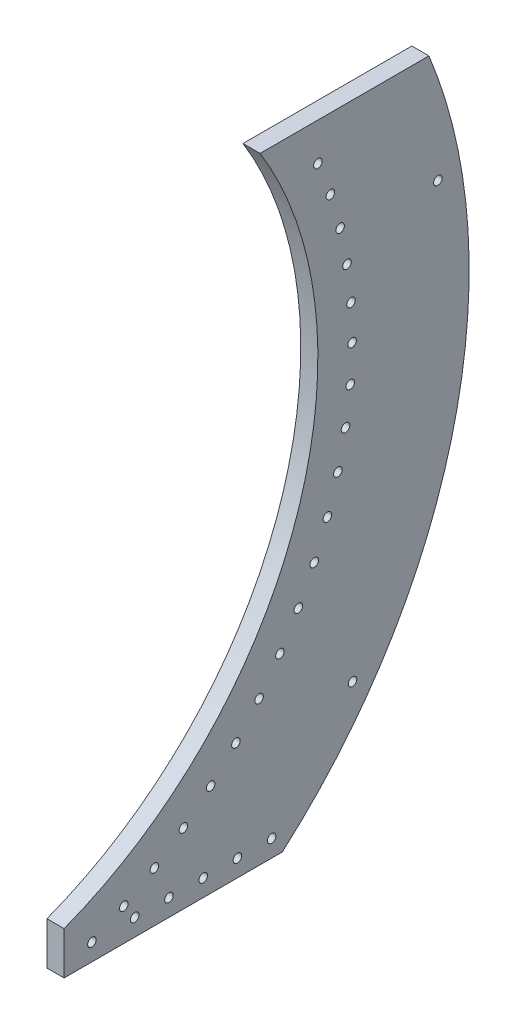
from build123d import *

# Parameters (mm, degrees)
BOSS_EXTRUDE1_DEPTH         = 12.7
SKETCH2_W                   = 323.85
SKETCH2_H                   = 152.4
CUT_EXTRUDE1_DEPTH          = 12.7
F_1_4_0_25_DIAMETER_HOLE1_D = 6.35
CUT_EXTRUDE2_DEPTH          = 13.7
SKETCH9_R                   = 3.175
CUT_EXTRUDE3_DEPTH          = 13.7
SKETCH10_R                  = 3.175
CUT_EXTRUDE4_DEPTH          = 13.7
LPATTERN1_COUNT             = 5
LPATTERN1_PITCH             = 25.4


with BuildPart() as part:
    # Sketch1 → Boss-Extrude1 (new body)
    with BuildSketch(Plane(origin=(0, 0, 0), x_dir=(0, 0, -1), z_dir=(1, 0, 0))):
        with BuildLine():
            Line((0, 609.6), (323.85, 609.6))
            Line((323.85, 609.6), (323.85, 0))
            Line((323.85, 0), (0, 0))
            Line((0, 0), (0, 31.75))
            ThreePointArc((0, 31.75), (188.340145046, 304.8), (0, 577.85))
            Line((0, 577.85), (0, 609.6))
        make_face()
    extrude(amount=BOSS_EXTRUDE1_DEPTH)

    # Sketch2 → Cut-Extrude1 (cut)
    with BuildSketch(Plane(origin=(12.7, 0, 0), x_dir=(0, 0, -1), z_dir=(1, 0, 0))):
        with Locations((161.925, 533.4)):
            Rectangle(SKETCH2_W, SKETCH2_H)
    extrude(amount=-CUT_EXTRUDE1_DEPTH, mode=Mode.SUBTRACT)

    # 1/4 (0.25) Diameter Hole1 (through all)
    with Locations(Plane(origin=(12.7, 0, 0), x_dir=(0, 0, -1), z_dir=(1, 0, 0))):
        with Locations((20.67422398, 12.7), (44.370645325, 23.973354386), (67.055185152, 37.165039515), (88.57288505, 52.184942803), (108.776757311, 68.93046308), (127.528789002, 87.287211463), (144.70088473, 107.129792746), (160.17574167, 128.32266198), (173.847650859, 150.721050378), (185.623219292, 174.171954236), (195.422007898, 198.515180102), (203.177081014, 223.584439059), (208.835463627, 249.208482649), (212.358503247, 275.212272671), (213.722133941, 301.418176873), (212.917040728, 327.647182356), (209.948723211, 353.720118416), (204.837458009, 379.458880463), (197.618160246, 404.687646654), (188.340145046, 429.234078933)):
            Hole(F_1_4_0_25_DIAMETER_HOLE1_D / 2)

    # Sketch8 → Cut-Extrude2 (cut, through all)
    with BuildSketch(Plane(origin=(12.7, 0, 0), x_dir=(0, 0, -1), z_dir=(1, 0, 0))):
        with BuildLine():
            Line((270.760801555, 457.2), (323.85, 457.2))
            Line((323.85, 457.2), (323.85, 0))
            Line((323.85, 0), (161.925, 0))
            ThreePointArc((161.925, 0), (289.589524386, 211.163746738), (270.760801555, 457.2))
        make_face()
    extrude(amount=-CUT_EXTRUDE2_DEPTH, mode=Mode.SUBTRACT)

    # Sketch9 → Cut-Extrude3 (cut, through all)
    with BuildSketch(Plane(origin=(12.7, 0, 0), x_dir=(0, 0, -1), z_dir=(1, 0, 0))):
        with Locations((214.065703753, 83.37972827)):
            Circle(SKETCH9_R)
        with Locations((277.383754924, 373.862081852)):
            Circle(SKETCH9_R)
    extrude(amount=-CUT_EXTRUDE3_DEPTH, mode=Mode.SUBTRACT)

    # Sketch10 → Cut-Extrude4 (cut, through all)
    with BuildSketch(Plane.ZY):
        with Locations((-154.03800305, 12.7)):
            Circle(SKETCH10_R)
    cut_extrude4 = extrude(amount=-CUT_EXTRUDE4_DEPTH, mode=Mode.SUBTRACT)

    # LPattern1: Cut-Extrude4 ×5
    with Locations(*[(0, 0, i * LPATTERN1_PITCH) for i in range(1, LPATTERN1_COUNT)]):
        add(cut_extrude4, mode=Mode.SUBTRACT)


solid = part.part
